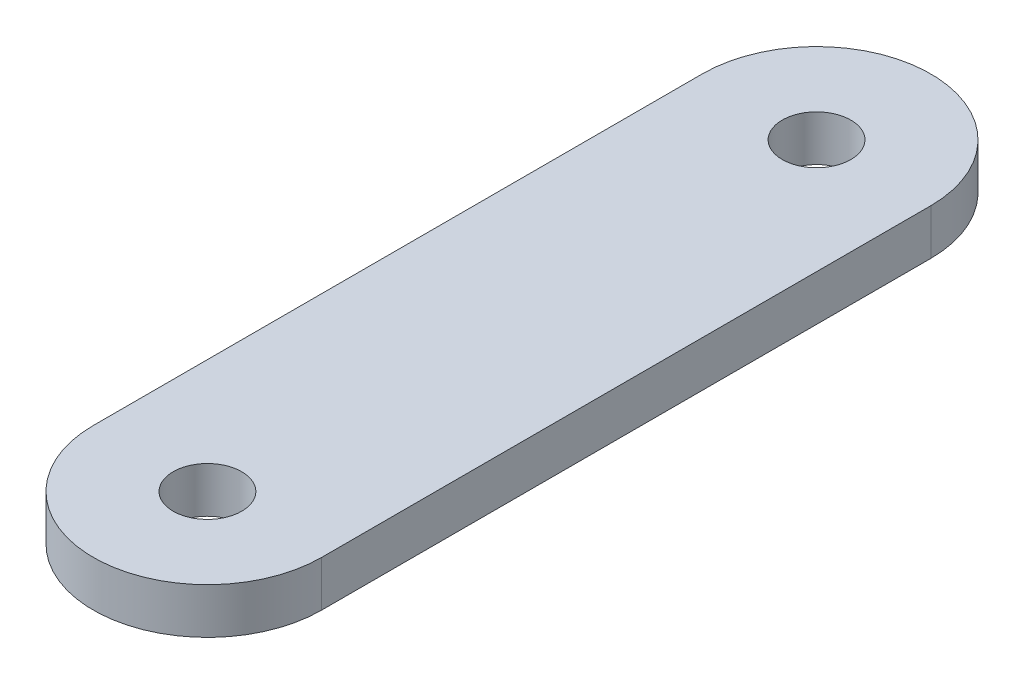
from build123d import *

# Parameters (mm, degrees)
SKETCH1_R           = 2.25
BOSS_EXTRUDE1_DEPTH = 3


with BuildPart() as part:
    # Sketch1 → Boss-Extrude1 (new body)
    with BuildSketch(Plane(origin=(0, 0, 0), x_dir=(1, 0, 0), z_dir=(0, 1, 0))):
        with BuildLine():
            Line((-7.5, 40), (-7.5, 0))
            ThreePointArc((-7.5, 0), (0, -7.5), (7.5, 0))
            Line((7.5, 0), (7.5, 40))
            ThreePointArc((7.5, 40), (0, 47.5), (-7.5, 40))
        make_face()
        Circle(SKETCH1_R, mode=Mode.SUBTRACT)
        with Locations((0, 40)):
            Circle(SKETCH1_R, mode=Mode.SUBTRACT)
    extrude(amount=BOSS_EXTRUDE1_DEPTH)


solid = part.part
